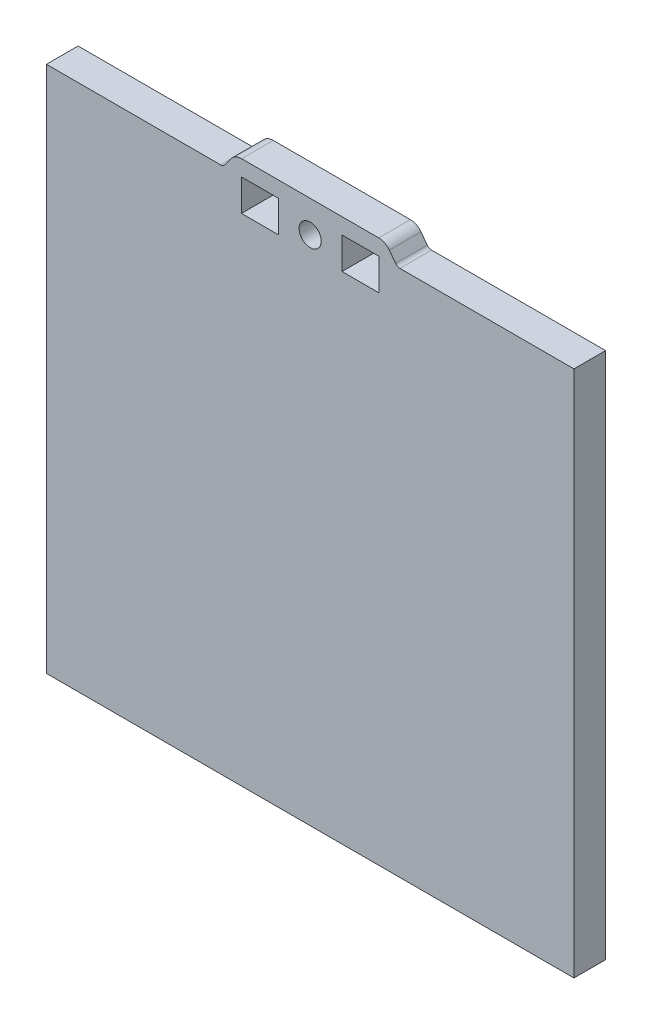
from build123d import *

# Parameters (mm, degrees)
SKETCH_1_W          = 100
SKETCH_1_H          = 100
EXTRUDE_1_DEPTH     = 6
EXTRUDE_2_DEPTH     = 6
SKETCH_3_R          = 2.1
SKETCH_3_W          = 7
SKETCH_3_H          = 6
CUT_EXTRUDE_1_DEPTH = 7


with BuildPart() as part:
    # Эскиз1 → Бобышка-Вытянуть1 (new body)
    with BuildSketch(Plane.XY):
        Rectangle(SKETCH_1_W, SKETCH_1_H)
    extrude(amount=EXTRUDE_1_DEPTH)

    # Эскиз2 → Бобышка-Вытянуть2 (add)
    with BuildSketch(Plane.XY):
        with BuildLine():
            Line((13, 53), (-13, 53))
            ThreePointArc((-13, 53), (-14.118033989, 52.736067977), (-15, 52))
            Line((-15, 52), (-16.2, 50.4))
            ThreePointArc((-16.2, 50.4), (-16.552786405, 50.105572809), (-17, 50))
            Line((-17, 50), (17, 50))
            ThreePointArc((17, 50), (16.552786405, 50.105572809), (16.2, 50.4))
            Line((16.2, 50.4), (15, 52))
            ThreePointArc((15, 52), (14.118033989, 52.736067977), (13, 53))
        make_face()
    extrude(amount=EXTRUDE_2_DEPTH)

    # Эскиз3 → Вырез-Вытянуть1 (cut, through all)
    with BuildSketch(Plane.XY.offset(6)):
        with Locations((0, 47)):
            Circle(SKETCH_3_R)
        with Locations((9.531849908, 47)):
            Rectangle(SKETCH_3_W, SKETCH_3_H)
        with Locations((-9.531849908, 47)):
            Rectangle(SKETCH_3_W, SKETCH_3_H)
    extrude(amount=-CUT_EXTRUDE_1_DEPTH, mode=Mode.SUBTRACT)


solid = part.part
